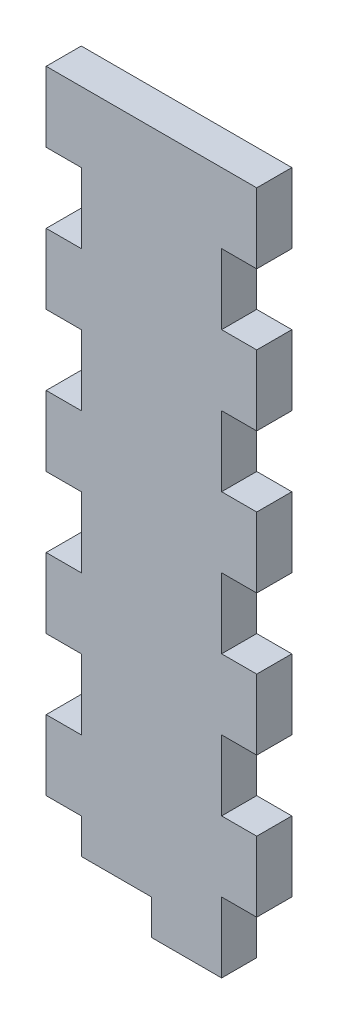
from build123d import *

# Parameters (mm, degrees)
SKETCH1_W           = 38.1
SKETCH1_H           = 127
BOSS_EXTRUDE1_DEPTH = 6.35
SKETCH2_W           = 6.35
SKETCH2_H           = 12.7
CUT_EXTRUDE1_DEPTH  = 7.35
LPATTERN1_COUNT     = 6
LPATTERN1_PITCH     = 25.4
SKETCH3_W           = 12.7
SKETCH3_H           = 6.35
CUT_EXTRUDE2_DEPTH  = 7.35


with BuildPart() as part:
    # Sketch1 → Boss-Extrude1 (new body)
    with BuildSketch(Plane.XY):
        with Locations((19.05, 63.5)):
            Rectangle(SKETCH1_W, SKETCH1_H)
    extrude(amount=BOSS_EXTRUDE1_DEPTH)

    # Sketch2 → Cut-Extrude1 (cut, through all)
    with BuildSketch(Plane.XY.offset(6.35)):
        with Locations((3.175, 6.35)):
            Rectangle(SKETCH2_W, SKETCH2_H)
        with Locations((34.925, 6.35)):
            Rectangle(SKETCH2_W, SKETCH2_H)
    cut_extrude1 = extrude(amount=-CUT_EXTRUDE1_DEPTH, mode=Mode.SUBTRACT)

    # LPattern1: Cut-Extrude1 ×6
    with Locations(*[(0, i * LPATTERN1_PITCH, 0) for i in range(1, LPATTERN1_COUNT)]):
        add(cut_extrude1, mode=Mode.SUBTRACT)

    # Sketch3 → Cut-Extrude2 (cut, through all)
    with BuildSketch(Plane.XY.offset(6.35)):
        with Locations((12.7, 3.175)):
            Rectangle(SKETCH3_W, SKETCH3_H)
    extrude(amount=-CUT_EXTRUDE2_DEPTH, mode=Mode.SUBTRACT)


solid = part.part
